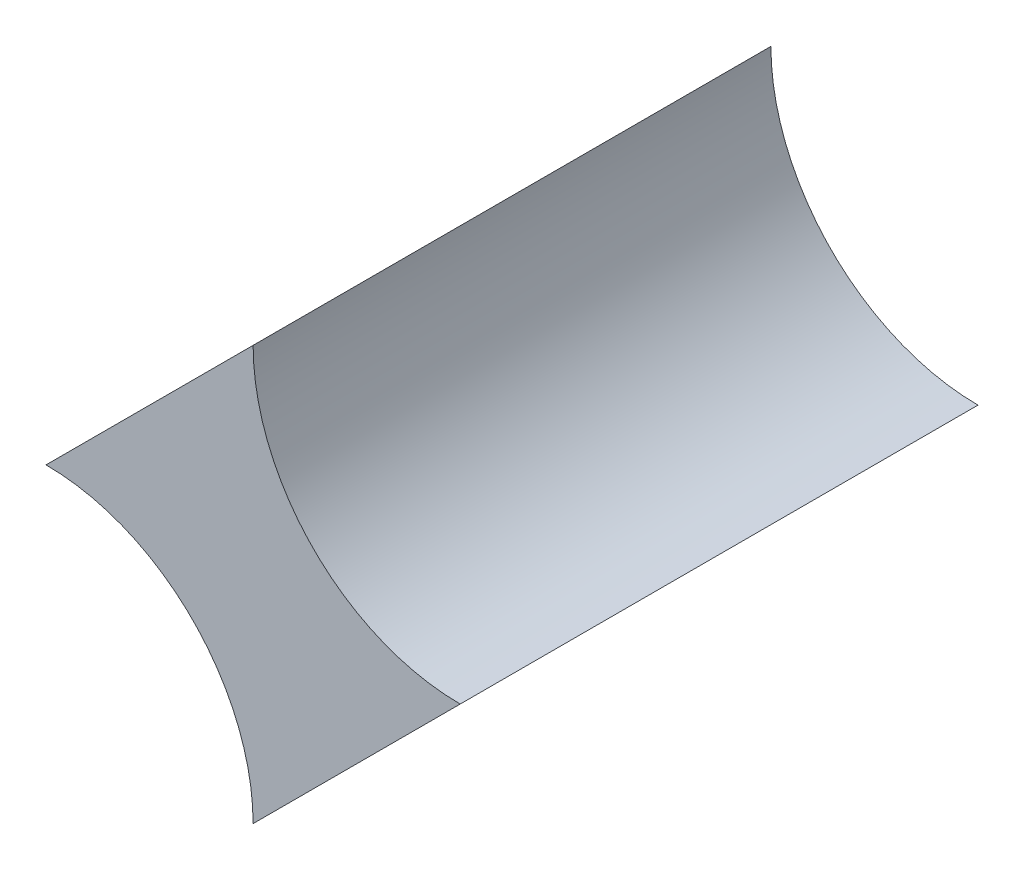
from build123d import *

# Parameters (mm, degrees)
BOSS_EXTRUDE2_DEPTH = 25


with BuildPart() as part:
    # Sketch1 → Boss-Extrude2 (new body)
    with BuildSketch(Plane.XY):
        with BuildLine():
            Line((-20, 0), (-10, 10))
            ThreePointArc((-10, 10), (-7.071067812, 2.928932188), (0, 0))
            Line((0, 0), (-10, -10))
            ThreePointArc((-10, -10), (-12.928932188, -2.928932188), (-20, 0))
        make_face()
    extrude(amount=BOSS_EXTRUDE2_DEPTH)


solid = part.part
